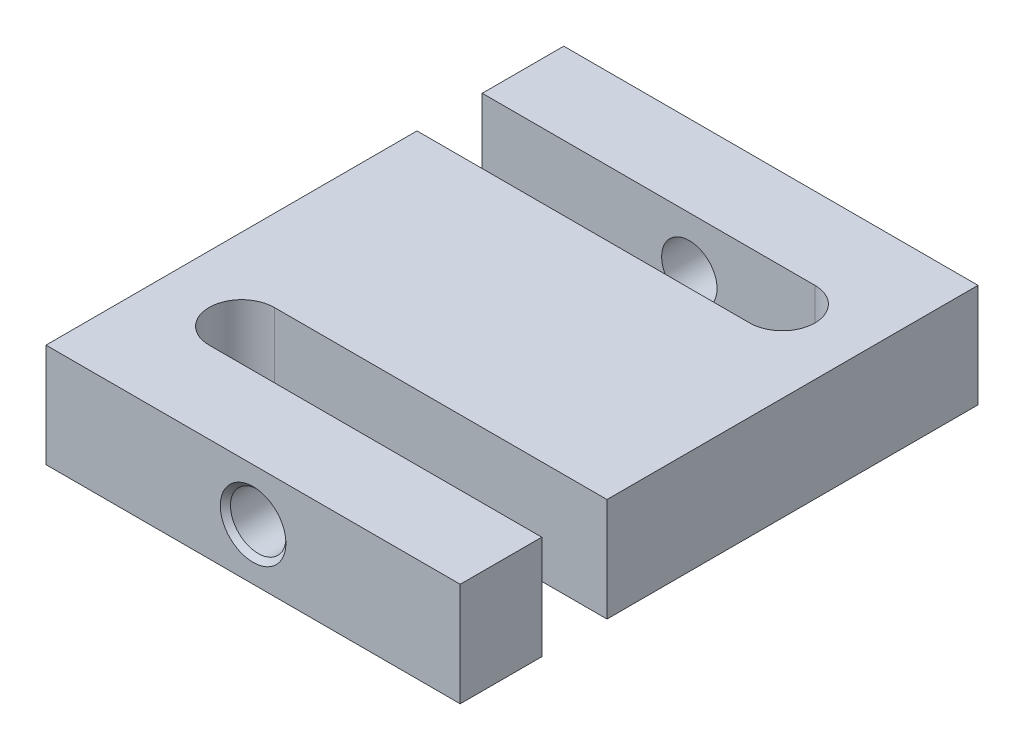
from build123d import *

# Parameters (mm, degrees)
SKETCH1_W                        = 50.8
SKETCH1_H                        = 63.5
BOSS_EXTRUDE1_DEPTH              = 12.7
M8X1_25_TAPPED_HOLE1_D           = 6.8
M8X1_25_TAPPED_HOLE1_DEPTH       = 15
M8X1_25_TAPPED_HOLE1_CSINK_D     = 8.05
M8X1_25_TAPPED_HOLE1_CSINK_ANGLE = 90
M8X1_25_TAPPED_HOLE1_TIP         = 2.042926105
M8X1_25_TAPPED_HOLE2_D           = 6.8
M8X1_25_TAPPED_HOLE2_DEPTH       = 15
M8X1_25_TAPPED_HOLE2_CSINK_D     = 8.05
M8X1_25_TAPPED_HOLE2_CSINK_ANGLE = 90
M8X1_25_TAPPED_HOLE2_TIP         = 2.042926105
CUT_EXTRUDE1_DEPTH               = 13.7


with BuildPart() as part:
    # Sketch1 → Boss-Extrude1 (new body)
    with BuildSketch(Plane(origin=(0, 0, 0), x_dir=(1, 0, 0), z_dir=(0, 1, 0))):
        with Locations((25.4, 31.75)):
            Rectangle(SKETCH1_W, SKETCH1_H)
    extrude(amount=BOSS_EXTRUDE1_DEPTH)

    # M8x1.25 Tapped Hole1
    with Locations(Plane(origin=(0, 0, -63.5), x_dir=(-1, 0, 0), z_dir=(0, 0, -1))):
        with Locations((-25.4, 6.35)):
            CounterSinkHole(M8X1_25_TAPPED_HOLE1_D / 2, M8X1_25_TAPPED_HOLE1_CSINK_D / 2, depth=M8X1_25_TAPPED_HOLE1_DEPTH, counter_sink_angle=M8X1_25_TAPPED_HOLE1_CSINK_ANGLE)
            with Locations((0, 0, -(M8X1_25_TAPPED_HOLE1_DEPTH + M8X1_25_TAPPED_HOLE1_TIP / 2))):  # 118° drill point
                Cone(0, M8X1_25_TAPPED_HOLE1_D / 2, M8X1_25_TAPPED_HOLE1_TIP, mode=Mode.SUBTRACT)

    # M8x1.25 Tapped Hole2
    with Locations(Plane.XY):
        with Locations((25.4, 6.35)):
            CounterSinkHole(M8X1_25_TAPPED_HOLE2_D / 2, M8X1_25_TAPPED_HOLE2_CSINK_D / 2, depth=M8X1_25_TAPPED_HOLE2_DEPTH, counter_sink_angle=M8X1_25_TAPPED_HOLE2_CSINK_ANGLE)
            with Locations((0, 0, -(M8X1_25_TAPPED_HOLE2_DEPTH + M8X1_25_TAPPED_HOLE2_TIP / 2))):  # 118° drill point
                Cone(0, M8X1_25_TAPPED_HOLE2_D / 2, M8X1_25_TAPPED_HOLE2_TIP, mode=Mode.SUBTRACT)

    # Sketch9 → Cut-Extrude1 (cut, through all)
    with BuildSketch(Plane(origin=(0, 12.7, 0), x_dir=(1, 0, 0), z_dir=(0, 1, 0))):
        with BuildLine():
            Line((0, 53.5), (40.8, 53.5))
            ThreePointArc((40.8, 53.5), (44.8, 49.5), (40.8, 45.5))
            Line((40.8, 45.5), (0, 45.5))
            Line((0, 45.5), (0, 53.5))
        make_face()
        with BuildLine():
            Line((50.8, 18), (10, 18))
            ThreePointArc((10, 18), (6, 14), (10, 10))
            Line((10, 10), (50.8, 10))
            Line((50.8, 10), (50.8, 18))
        make_face()
    extrude(amount=-CUT_EXTRUDE1_DEPTH, mode=Mode.SUBTRACT)


solid = part.part
